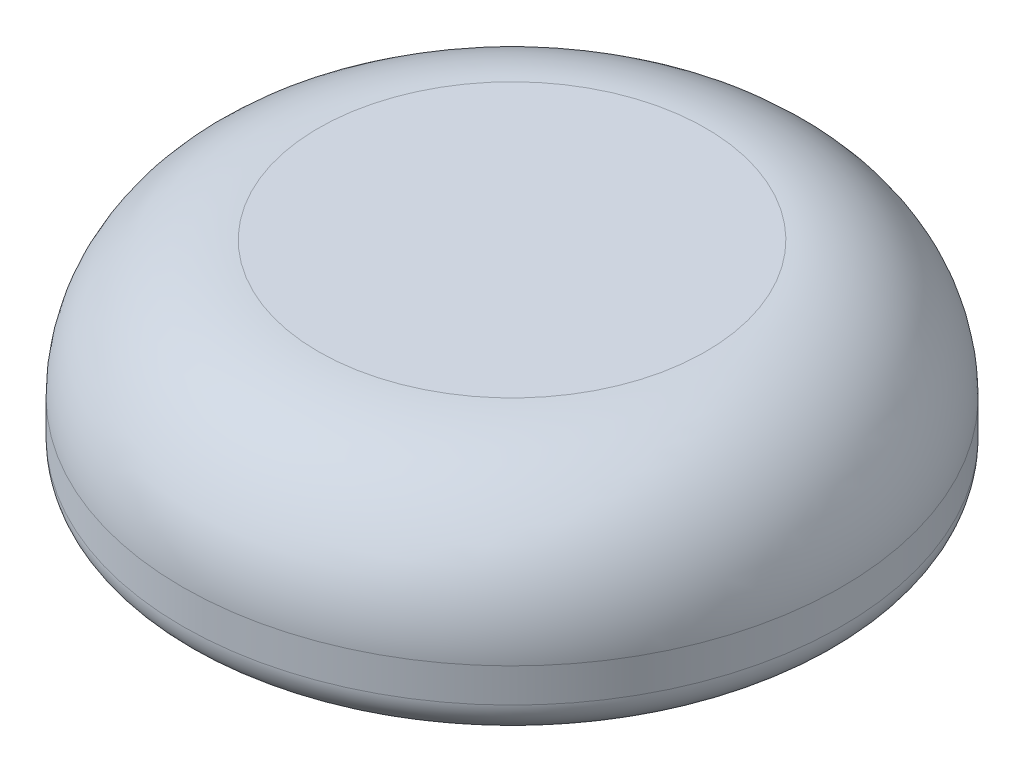
from build123d import *


with BuildPart() as part:
    # Sketch3 → Revolve1 (revolve)
    with BuildSketch(Plane(origin=(0, 0, 0), x_dir=(0, 0, -1), z_dir=(1, 0, 0))):
        with BuildLine():
            Line((12.319000296, -5.080996249), (12.319000296, -6.349750932))
            ThreePointArc((12.319000296, -6.349750932), (11.946952958, -7.247952662), (11.048751227, -7.62))
            Line((11.048751227, -7.62), (10.795249364, -7.62))
            ThreePointArc((10.795249364, -7.62), (9.897047634, -7.247952662), (9.525000296, -6.349750932))
            Line((9.525000296, -6.349750932), (9.525000296, -4.68336138))
            ThreePointArc((9.525000296, -4.68336138), (9.684048002, -3.333611598), (8.534504688, -2.60858))
            Line((8.534504688, -2.60858), (0, -2.60858))
            Line((0, -2.60858), (0, 0))
            Line((0, 0), (7.238004047, 0))
            ThreePointArc((7.238004047, 0), (10.83081095, -1.488189346), (12.319000296, -5.080996249))
        make_face()
    revolve(axis=Axis((0, -2.60858, 0), (0, -1, 0)))


solid = part.part
